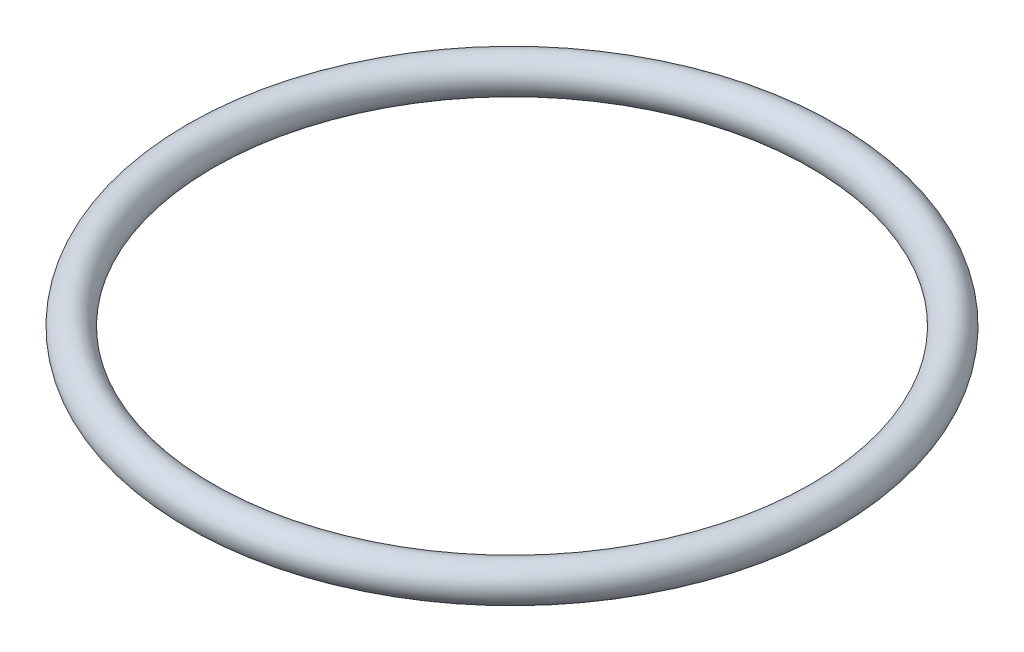
from build123d import *

# Parameters (mm, degrees)
SKETCH1_R = 2.667


with BuildPart() as part:
    # Sweep1: sweep along a path in Sketch2
    with BuildLine(Plane(origin=(0, 0, 0), x_dir=(1, 0, 0), z_dir=(0, 1, 0))) as sweep1_path:
        CenterArc((46.5455, 0), 46.5455, 0, 360)
    # Sketch1 → Sweep1 (sweep)
    with BuildSketch(Plane.XY):
        Circle(SKETCH1_R)
    sweep(path=sweep1_path.line)


solid = part.part
